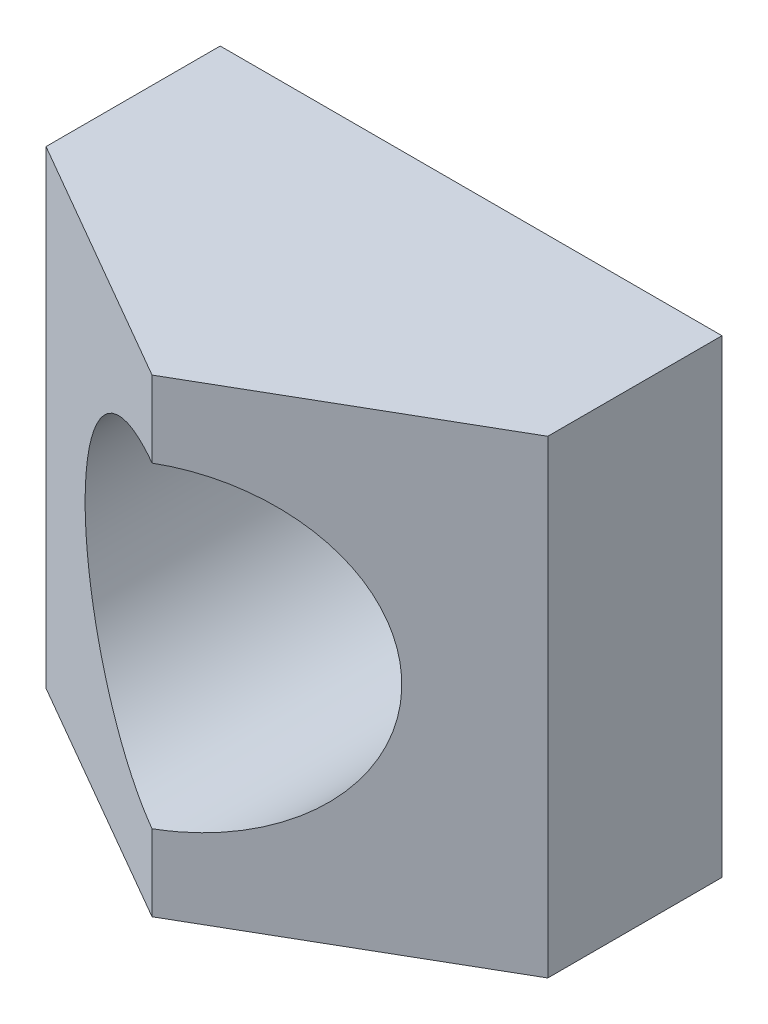
from build123d import *

# Parameters (mm, degrees)
BOSS_EXTRUDE1_DEPTH     = 4
SKETCH2_R               = 2.7
CUT_EXTRUDE2_DEPTH      = 8.662003654
CUT_EXTRUDE2_DEPTH_BACK = 8.662003654


with BuildPart() as part:
    # Sketch1 → Boss-Extrude1 (new, symmetric)
    with BuildSketch(Plane(origin=(0, 0, 0), x_dir=(1, 0, 0), z_dir=(0, 1, 0))):
        Polygon((4.278165495, -2.47), (4.278165495, 2.47), (0, 4.94), (-4.278165495, 2.47), (-4.278165495, -2.47), (0, -4.94), align=None)
    extrude(amount=BOSS_EXTRUDE1_DEPTH, both=True)

    # SurfaceCut1
    split(bisect_by=Plane.XY.offset(-0.5), keep=Keep.TOP)

    # Sketch2 → Cut-Extrude2 (cut, two sides)
    with BuildSketch(Plane.XY) as cut_extrude2_sk:
        with Locations(Location((0, 0, 0), (0, 0, 270))):
            Circle(SKETCH2_R)
    extrude(amount=CUT_EXTRUDE2_DEPTH, mode=Mode.SUBTRACT)
    extrude(cut_extrude2_sk.sketch, amount=-CUT_EXTRUDE2_DEPTH_BACK, mode=Mode.SUBTRACT)


solid = part.part
